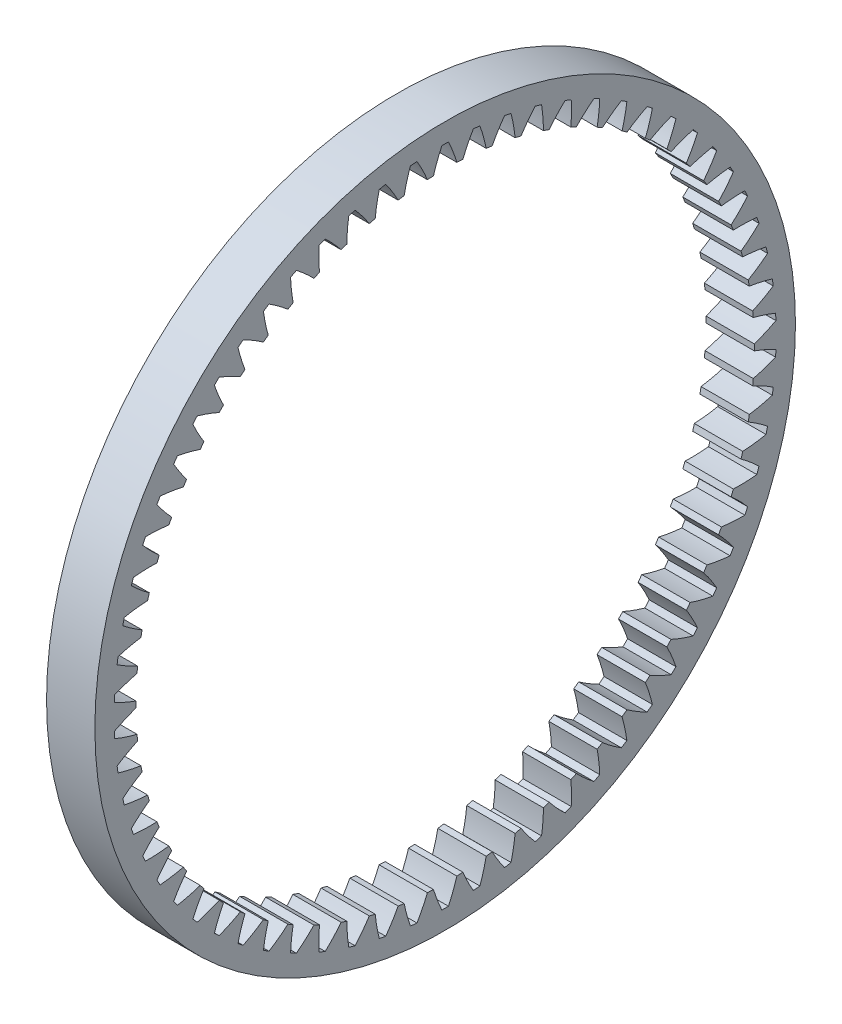
from build123d import *

# Parameters (mm, degrees)
BASPROSKE_W     = 10
BASPROSKE_H     = 8.5
TOOTHCUT_DEPTH  = 104.01698889
TEETHCUTS_COUNT = 66
TEETHCUTS_ANGLE = 354.545454545


with BuildPart() as part:
    # BasProSke → Base-Revolve (revolve)
    with BuildSketch(Plane(origin=(0, 0, 0), x_dir=(1, 0, 0), z_dir=(0, 1, 0))):
        with Locations((5, 68.25)):
            Rectangle(BASPROSKE_W, BASPROSKE_H)
    revolve(axis=Axis((-10, 0, 0), (1, 0, 0)))

    # TooCutSke → ToothCut (cut, through all)
    with BuildSketch(Plane(origin=(0, 0, 0), x_dir=(0, 0, -1), z_dir=(1, 0, 0))):
        with BuildLine():
            ThreePointArc((2.423343546, 63.928685668), (1.63718033, 66.24545285), (0.681537513, 68.497609503))
            ThreePointArc((0.681537513, 68.497609503), (0, 68.501), (-0.681537513, 68.497609503))
            ThreePointArc((-0.681537513, 68.497609503), (-1.63718033, 66.24545285), (-2.423343546, 63.928685668))
            ThreePointArc((-2.423343546, 63.928685668), (0, 63.9746), (2.423343546, 63.928685668))
        make_face()
    toothcut = extrude(amount=TOOTHCUT_DEPTH, mode=Mode.SUBTRACT)

    # TeethCuts: ToothCut ×66 about axis
    teethcuts_axis = Axis((-10, 0, 0), (1, 0, 0))
    for i in range(1, TEETHCUTS_COUNT):
        add(toothcut.rotate(teethcuts_axis, i * TEETHCUTS_ANGLE / (TEETHCUTS_COUNT - 1)), mode=Mode.SUBTRACT)


solid = part.part
